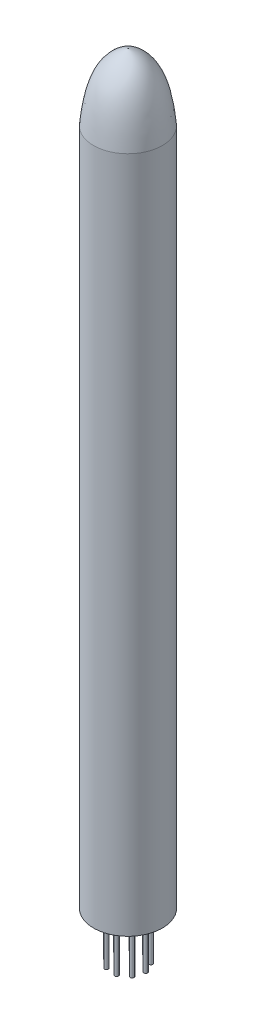
from build123d import *

# Parameters (mm, degrees)
SKETCH_2_R               = 0.2
EXTRUDE_1_DEPTH          = 5
PATTERN_CIRCULAR_1_COUNT = 9


with BuildPart() as part:
    # 草图1 → 旋转1 (revolve)
    with BuildSketch(Plane.XY):
        with BuildLine():
            Line((-3.6, 71), (-3.6, 0))
            Line((-3.6, 0), (0, 0))
            Line((0, 0), (0, 78))
            add(Edge.make_bspline(
                [(-3.6, 71), (-3.337937783, 73.551680107), (-2.931620403, 77.076293538), (0, 78)],
                knots=[0, 0, 0, 0, 1, 1, 1, 1], degree=3))
        make_face()
    revolve(axis=Axis((0, 8.263328558, 0), (0, -1, 0)))

    # 草图2 → 凸台-拉伸1 (add)
    with BuildSketch(Plane.XZ):
        with Locations((-0.987826351, -1.383545843)):
            Circle(SKETCH_2_R)
    extrude_1 = extrude(amount=EXTRUDE_1_DEPTH)

    # 阵列(圆周)1: 凸台-拉伸1 ×9 about axis
    pattern_circular_1_axis = Axis((0, 0, 0), (0, 1, 0))
    for i in range(1, PATTERN_CIRCULAR_1_COUNT):
        add(extrude_1.rotate(pattern_circular_1_axis, i * 360 / PATTERN_CIRCULAR_1_COUNT))


solid = part.part
